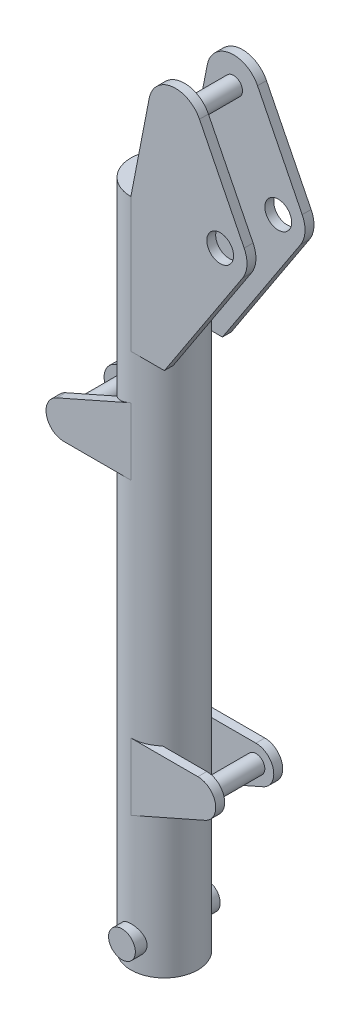
from build123d import *

# Parameters (mm, degrees)
SKETCH2_R           = 75
BOSS_EXTRUDE1_DEPTH = 1500
SHELL4_T            = 10
BOSS_EXTRUDE2_START = 75
SKETCH3_R           = 30
BOSS_EXTRUDE2_DEPTH = 20
SKETCH10_R          = 30
BOSS_EXTRUDE3_DEPTH = 95
SKETCH12_R          = 20
BOSS_EXTRUDE4_DEPTH = 75


with BuildPart() as part:
    # Sketch2 → Boss-Extrude1 (new body)
    with BuildSketch(Plane(origin=(0, 0, 0), x_dir=(1, 0, 0), z_dir=(0, 1, 0))):
        Circle(SKETCH2_R)
    extrude(amount=BOSS_EXTRUDE1_DEPTH)

    # Shell4 (no face opened: a closed hollow body)
    add(offset(amount=-SHELL4_T, mode=Mode.PRIVATE), mode=Mode.SUBTRACT)

    # Sketch3 → Boss-Extrude2 (add)
    with BuildSketch(Plane.XY.offset(BOSS_EXTRUDE2_START)):
        with BuildLine():
            Line((0, 450), (150, 450))
            ThreePointArc((150, 450), (189.137774485, 418.260424226), (166.164731025, 373.41173042))
            Line((166.164731025, 373.41173042), (0, 300))
            Line((0, 300), (0, 450))
        make_face()
        with BuildLine():
            Line((0, 1100), (0, 950))
            Line((0, 950), (-150, 950))
            ThreePointArc((-150, 950), (-189.137774485, 981.739575774), (-166.164731025, 1026.58826958))
            Line((-166.164731025, 1026.58826958), (0, 1100))
        make_face()
        with BuildLine():
            Line((0, 1200), (0, 1500))
            Line((0, 1500), (41.102417852, 1711.448791074))
            ThreePointArc((41.102417852, 1711.448791074), (91.875322735, 1759.447368481), (153.66563146, 1726.83281573))
            Line((153.66563146, 1726.83281573), (253.66563146, 1526.83281573))
            ThreePointArc((253.66563146, 1526.83281573), (259.897670219, 1496.497272164), (250.172245693, 1467.094897628))
            Line((250.172245693, 1467.094897628), (75, 1200))
            Line((75, 1200), (0, 1200))
        make_face()
        with Locations((200, 1500)):
            Circle(SKETCH3_R, mode=Mode.SUBTRACT)
    boss_extrude2 = extrude(amount=-BOSS_EXTRUDE2_DEPTH)

    # Mirror11: Boss-Extrude2 across plane
    add(boss_extrude2.mirror(Plane(origin=(0, 0, 0), x_dir=(1, 0, 0), z_dir=(0, 0, -1))))

    # Sketch10 → Boss-Extrude3 (add, symmetric)
    with BuildSketch(Plane.XY):
        with Locations((0, 60)):
            Circle(SKETCH10_R)
    extrude(amount=BOSS_EXTRUDE3_DEPTH, both=True)

    # Sketch12 → Boss-Extrude4 (add, symmetric)
    with BuildSketch(Plane.XY):
        with Locations((150, 410)):
            Circle(SKETCH12_R)
        with Locations((100, 1700)):
            Circle(SKETCH12_R)
        with Locations((-150, 990)):
            Circle(SKETCH12_R)
    extrude(amount=BOSS_EXTRUDE4_DEPTH, both=True)


solid = part.part
